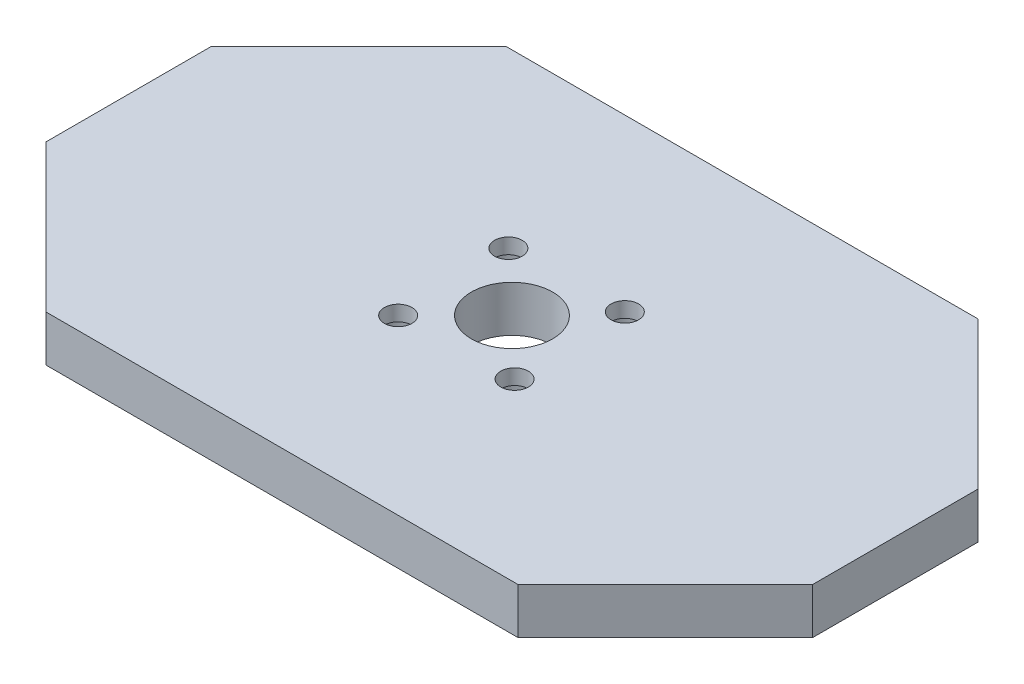
from build123d import *

# Parameters (mm, degrees)
SALIENTE_EXTRUIR1_DEPTH = 6
CORTAR_EXTRUIR1_REACH   = 8
CROQUIS2_R              = 5.3
CROQUIS2_R_2            = 1.8
CROQUIS3_R              = 4
CROQUIS3_R_2            = 2.910883151
CROQUIS3_R_3            = 2.97880362
CORTAR_EXTRUIR2_DEPTH   = 4


with BuildPart() as part:
    # Croquis1 → Saliente-Extruir1 (new body)
    with BuildSketch(Plane(origin=(0, 0, 0), x_dir=(1, 0, 0), z_dir=(0, 1, 0))):
        Polygon((-50, 10.783872382), (-30.783872382, 30), (30.783872382, 30), (50, 10.783872382), (50, -10.783872382), (30.783872382, -30), (-30.783872382, -30), (-50, -10.783872382), align=None)
    extrude(amount=SALIENTE_EXTRUIR1_DEPTH)

    # Croquis2 → Cortar-Extruir1 (cut, up to next)
    with BuildSketch(Plane(origin=(0, 6, 0), x_dir=(1, 0, 0), z_dir=(0, 1, 0)), mode=Mode.PRIVATE) as cortar_extruir1_sk1:
        Circle(CROQUIS2_R)
    cortar_extruir1_tool1 = extrude(cortar_extruir1_sk1.sketch, amount=-CORTAR_EXTRUIR1_REACH, mode=Mode.PRIVATE) & part.part
    add(cortar_extruir1_tool1.solids().sort_by_distance((0, 6, 0))[0], mode=Mode.SUBTRACT)
    # Croquis2 → Cortar-Extruir1 (cut, up to next)
    with BuildSketch(Plane(origin=(0, 6, 0), x_dir=(1, 0, 0), z_dir=(0, 1, 0)), mode=Mode.PRIVATE) as cortar_extruir1_sk2:
        with Locations((-7.424621202, -7.424621202)):
            Circle(CROQUIS2_R_2)
    cortar_extruir1_tool2 = extrude(cortar_extruir1_sk2.sketch, amount=-CORTAR_EXTRUIR1_REACH, mode=Mode.PRIVATE) & part.part
    add(cortar_extruir1_tool2.solids().sort_by_distance((-7.424621, 6, 7.424621))[0], mode=Mode.SUBTRACT)
    # Croquis2 → Cortar-Extruir1 (cut, up to next)
    with BuildSketch(Plane(origin=(0, 6, 0), x_dir=(1, 0, 0), z_dir=(0, 1, 0)), mode=Mode.PRIVATE) as cortar_extruir1_sk3:
        with Locations((-7.827733398, 7.357422898)):
            Circle(CROQUIS2_R_2)
    cortar_extruir1_tool3 = extrude(cortar_extruir1_sk3.sketch, amount=-CORTAR_EXTRUIR1_REACH, mode=Mode.PRIVATE) & part.part
    add(cortar_extruir1_tool3.solids().sort_by_distance((-7.827733, 6, -7.357423))[0], mode=Mode.SUBTRACT)
    # Croquis2 → Cortar-Extruir1 (cut, up to next)
    with BuildSketch(Plane(origin=(0, 6, 0), x_dir=(1, 0, 0), z_dir=(0, 1, 0)), mode=Mode.PRIVATE) as cortar_extruir1_sk4:
        with Locations((6.954310702, 7.760535094)):
            Circle(CROQUIS2_R_2)
    cortar_extruir1_tool4 = extrude(cortar_extruir1_sk4.sketch, amount=-CORTAR_EXTRUIR1_REACH, mode=Mode.PRIVATE) & part.part
    add(cortar_extruir1_tool4.solids().sort_by_distance((6.954311, 6, -7.760535))[0], mode=Mode.SUBTRACT)
    # Croquis2 → Cortar-Extruir1 (cut, up to next)
    with BuildSketch(Plane(origin=(0, 6, 0), x_dir=(1, 0, 0), z_dir=(0, 1, 0)), mode=Mode.PRIVATE) as cortar_extruir1_sk5:
        with Locations((7.357422898, -7.021509007)):
            Circle(CROQUIS2_R_2)
    cortar_extruir1_tool5 = extrude(cortar_extruir1_sk5.sketch, amount=-CORTAR_EXTRUIR1_REACH, mode=Mode.PRIVATE) & part.part
    add(cortar_extruir1_tool5.solids().sort_by_distance((7.357423, 6, 7.021509))[0], mode=Mode.SUBTRACT)

    # Croquis3 → Cortar-Extruir2 (cut)
    with BuildSketch(Plane.XZ):
        with Locations((7.357422898, 7.021509007)):
            Circle(CROQUIS3_R)
        with Locations((6.954310702, -7.760535094)):
            Circle(CROQUIS3_R_2)
        with Locations((-7.424621202, 7.424621202)):
            Circle(CROQUIS3_R_3)
        with Locations((-7.827733398, -7.357422898)):
            Circle(CROQUIS3_R)
    extrude(amount=-CORTAR_EXTRUIR2_DEPTH, mode=Mode.SUBTRACT)


solid = part.part
